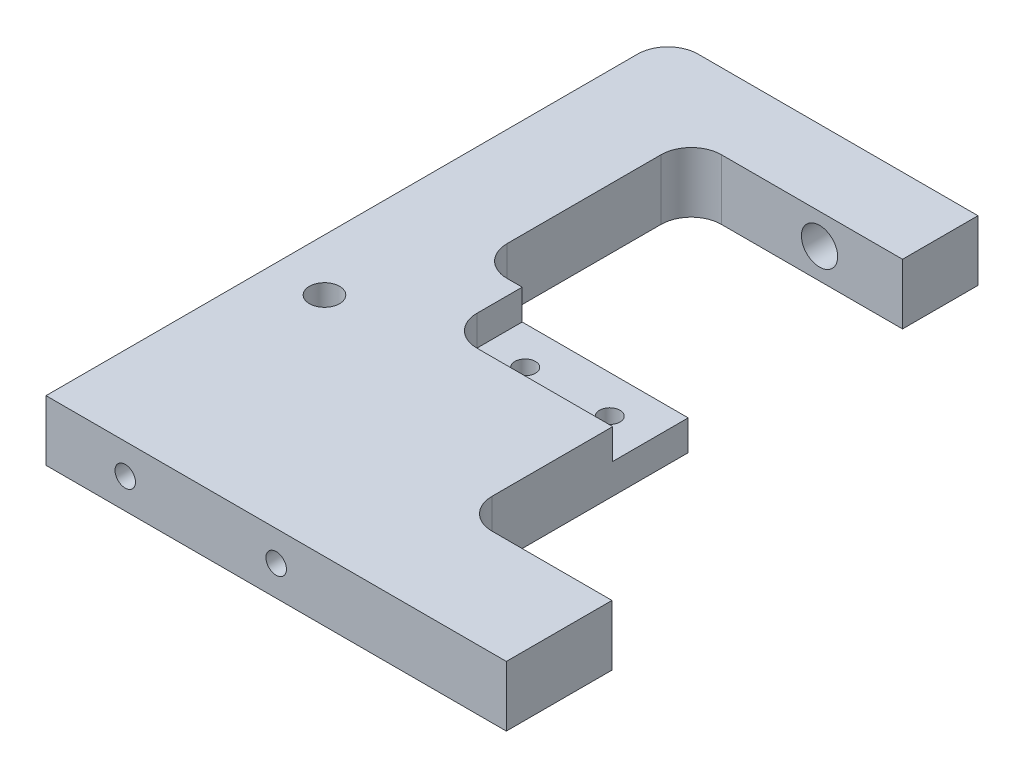
from build123d import *

# Parameters (mm, degrees)
LINEAR_AUSTRAGEN1_DEPTH              = 20
LINEAR_AUSTRAGEN2_DEPTH              = 10
F_12_0_12_DURCHMESSER_BOHRUNG1_D     = 12
F_12_0_12_DURCHMESSER_BOHRUNG1_DEPTH = 25
F_10_0_10_DURCHMESSER_BOHRUNG1_D     = 10
M6_GEWINDEBOHRUNG1_REACH             = 154.5
M6_GEWINDEBOHRUNG1_BORE_R            = 2.5
M8_GEWINDEBOHRUNG1_D                 = 6.8
M8_GEWINDEBOHRUNG1_DEPTH             = 22.25
M8_GEWINDEBOHRUNG1_TIP               = 2.042926105
M6_GEWINDEBOHRUNG3_D                 = 5
M6_GEWINDEBOHRUNG3_DEPTH             = 17
M6_GEWINDEBOHRUNG3_TIP               = 1.502151548
M8_GEWINDEBOHRUNG2_D                 = 6.8
M8_GEWINDEBOHRUNG2_DEPTH             = 22.25
M8_GEWINDEBOHRUNG2_TIP               = 2.042926105


with BuildPart() as part:
    # Skizze1 → Linear austragen1 (new body)
    with BuildSketch(Plane(origin=(0, 0, 0), x_dir=(1, 0, 0), z_dir=(0, 1, 0))):
        with BuildLine():
            Line((0, 0), (0, 196))
            ThreePointArc((0, 196), (2.928932188, 203.071067812), (10, 206))
            Line((10, 206), (102.75, 206))
            Line((102.75, 206), (102.75, 181))
            Line((102.75, 181), (42.75, 181))
            ThreePointArc((42.75, 181), (35.678932188, 178.071067812), (32.75, 171))
            Line((32.75, 171), (32.75, 120))
            ThreePointArc((32.75, 120), (35.678932188, 112.928932188), (42.75, 110))
            Line((42.75, 110), (102.75, 110))
            Line((102.75, 110), (102.75, 45))
            ThreePointArc((102.75, 45), (105.678932188, 37.928932188), (112.75, 35))
            Line((112.75, 35), (152.5, 35))
            Line((152.5, 35), (152.5, 0))
            Line((152.5, 0), (102.75, 0))
            Line((102.75, 0), (0, 0))
        make_face()
    extrude(amount=LINEAR_AUSTRAGEN1_DEPTH)

    # Skizze20 → Linear austragen2 (cut)
    with BuildSketch(Plane(origin=(0, 20, 0), x_dir=(1, 0, 0), z_dir=(0, 1, 0))):
        with BuildLine():
            Line((47.75, 110), (47.75, 95))
            ThreePointArc((47.75, 95), (50.678932188, 87.928932188), (57.75, 85))
            Line((57.75, 85), (102.75, 85))
            Line((102.75, 85), (102.75, 110))
            Line((102.75, 110), (47.75, 110))
        make_face()
    extrude(amount=-LINEAR_AUSTRAGEN2_DEPTH, mode=Mode.SUBTRACT)

    # Ø12.0 (12) Durchmesser Bohrung1
    with Locations(Plane(origin=(0, 0, -206), x_dir=(-1, 0, 0), z_dir=(0, 0, -1))):
        with Locations((-75.25, 10)):
            Hole(F_12_0_12_DURCHMESSER_BOHRUNG1_D / 2, depth=F_12_0_12_DURCHMESSER_BOHRUNG1_DEPTH)

    # Ø10.0 (10) Durchmesser Bohrung1 (through all)
    with Locations(Plane(origin=(51, 20, 10), x_dir=(1, 0, 0), z_dir=(0, 1, 0))):
        with Locations((-33.75, 85)):
            Hole(F_10_0_10_DURCHMESSER_BOHRUNG1_D / 2)

    # M6 Gewindebohrung1 bore → M6 Gewindebohrung1 (cut, up to next)
    with BuildSketch(Plane.ZY, mode=Mode.PRIVATE) as m6_gewindebohrung1_sk1:
        with Locations((-75, 10)):
            Circle(M6_GEWINDEBOHRUNG1_BORE_R)
    m6_gewindebohrung1_tool1 = extrude(m6_gewindebohrung1_sk1.sketch, amount=-M6_GEWINDEBOHRUNG1_REACH, mode=Mode.PRIVATE) & part.part
    add(m6_gewindebohrung1_tool1.solids().sort_by_distance((0, 10, -75))[0], mode=Mode.SUBTRACT)

    # M8 Gewindebohrung1
    with Locations(Plane(origin=(51.25, 10, 0), x_dir=(1, 0, 0), z_dir=(0, 0, 1))):
        with Locations((-25, 0), (25, 0)):
            Hole(M8_GEWINDEBOHRUNG1_D / 2, depth=M8_GEWINDEBOHRUNG1_DEPTH)
            with Locations((0, 0, -(M8_GEWINDEBOHRUNG1_DEPTH + M8_GEWINDEBOHRUNG1_TIP / 2))):  # 118° drill point
                Cone(0, M8_GEWINDEBOHRUNG1_D / 2, M8_GEWINDEBOHRUNG1_TIP, mode=Mode.SUBTRACT)

    # M6 Gewindebohrung3
    with Locations(Plane(origin=(6.209471485, 2.149988387, -35), x_dir=(-1, 0, 0), z_dir=(0, 0, -1))):
        with Locations((-137.290528515, 7.850011613), (-124.790528515, 7.850011613)):
            Hole(M6_GEWINDEBOHRUNG3_D / 2, depth=M6_GEWINDEBOHRUNG3_DEPTH)
            with Locations((0, 0, -(M6_GEWINDEBOHRUNG3_DEPTH + M6_GEWINDEBOHRUNG3_TIP / 2))):  # 118° drill point
                Cone(0, M6_GEWINDEBOHRUNG3_D / 2, M6_GEWINDEBOHRUNG3_TIP, mode=Mode.SUBTRACT)

    # M8 Gewindebohrung2
    with Locations(Plane(origin=(0, 10, 0), x_dir=(-1, 0, 0), z_dir=(0, 1, 0))):
        with Locations((-61.25, -97.5), (-89.25, -97.5)):
            Hole(M8_GEWINDEBOHRUNG2_D / 2, depth=M8_GEWINDEBOHRUNG2_DEPTH)
            with Locations((0, 0, -(M8_GEWINDEBOHRUNG2_DEPTH + M8_GEWINDEBOHRUNG2_TIP / 2))):  # 118° drill point
                Cone(0, M8_GEWINDEBOHRUNG2_D / 2, M8_GEWINDEBOHRUNG2_TIP, mode=Mode.SUBTRACT)


solid = part.part
